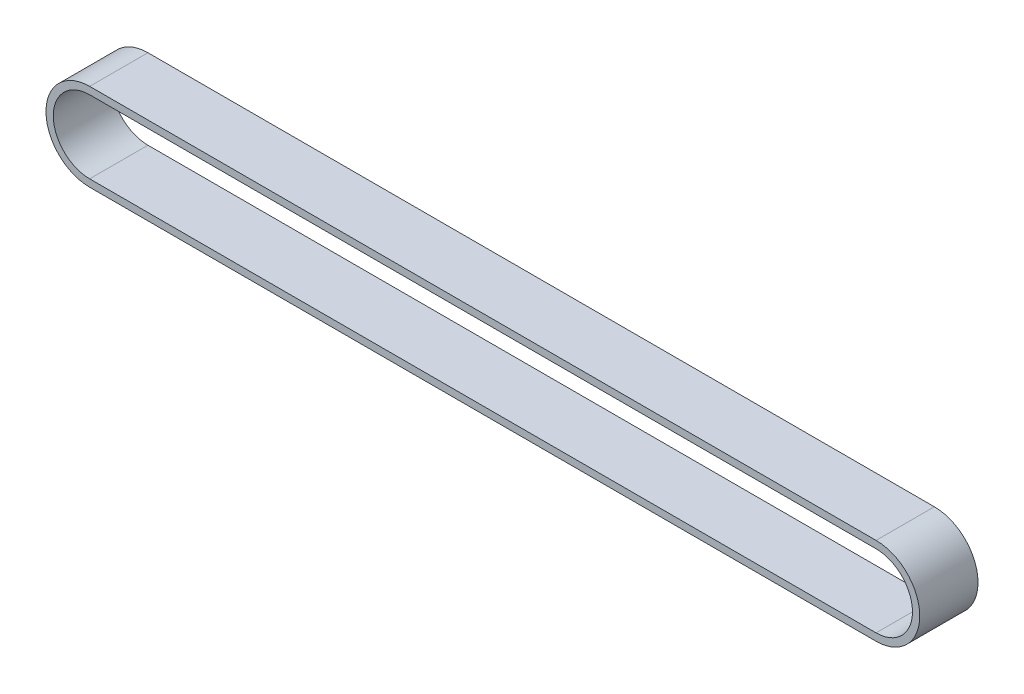
from build123d import *

# Parameters (mm, degrees)
RESSALTO_EXTRUS_O1_DEPTH = 8


with BuildPart() as part:
    # Esboço1 → Ressalto-extrusão1 (new body)
    with BuildSketch(Plane.XY):
        with BuildLine():
            Line((-18.82628943, 6), (89.17371057, 6))
            ThreePointArc((89.17371057, 6), (95.17371057, 0), (89.17371057, -6))
            Line((89.17371057, -6), (-18.82628943, -6))
            ThreePointArc((-18.82628943, -6), (-24.82628943, 0), (-18.82628943, 6))
        make_face()
        with BuildLine():
            Line((-18.82628943, 5), (89.17371057, 5))
            ThreePointArc((89.17371057, 5), (94.17371057, 0), (89.17371057, -5))
            Line((89.17371057, -5), (-18.82628943, -5))
            ThreePointArc((-18.82628943, -5), (-23.82628943, 0), (-18.82628943, 5))
        make_face(mode=Mode.SUBTRACT)
    extrude(amount=RESSALTO_EXTRUS_O1_DEPTH)


solid = part.part
